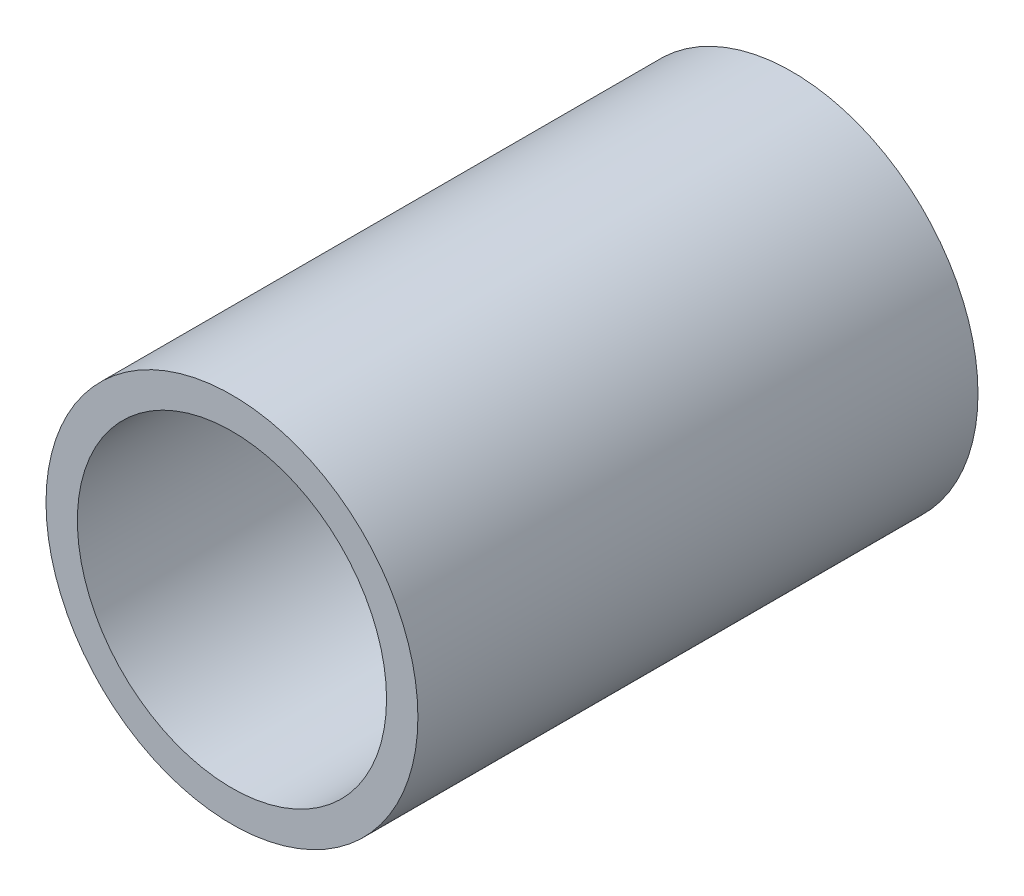
from build123d import *

# Parameters (mm, degrees)
SKETCH1_R           = 21.082
SKETCH1_R_2         = 17.526
EXTRUDE_THIN1_DEPTH = 31.75


with BuildPart() as part:
    # Sketch1 → Extrude-Thin1 (new body, symmetric)
    with BuildSketch(Plane.XY):
        Circle(SKETCH1_R)
        Circle(SKETCH1_R_2, mode=Mode.SUBTRACT)
    extrude(amount=EXTRUDE_THIN1_DEPTH, both=True)


solid = part.part
